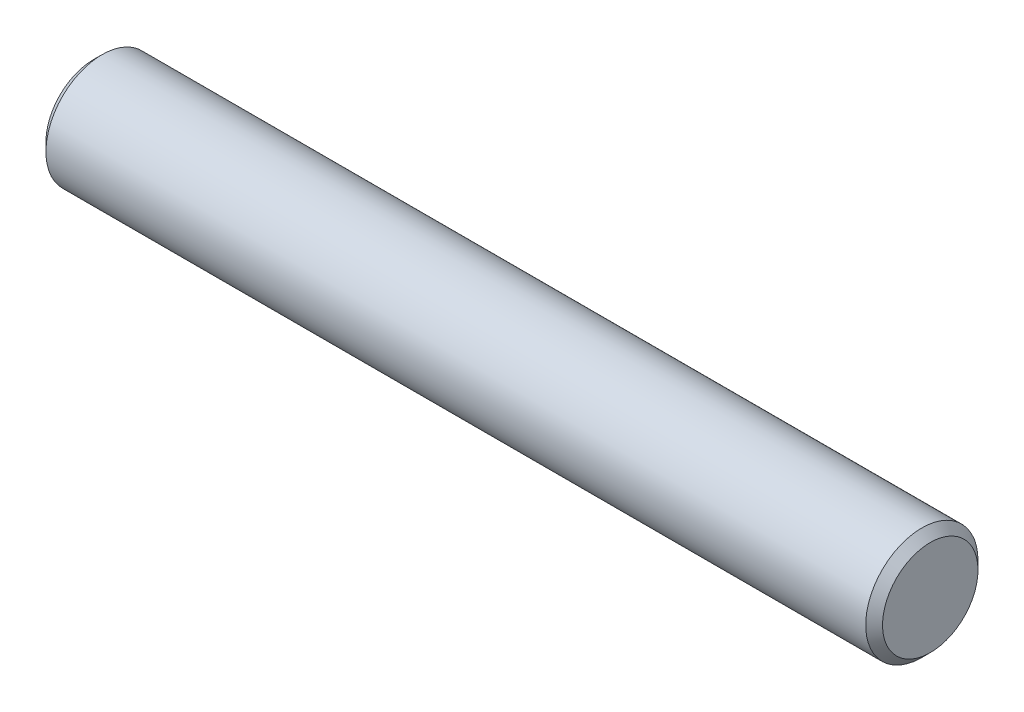
from build123d import *

# Parameters (mm, degrees)
SKETCH1_R           = 1
BOSS_EXTRUDE1_DEPTH = 7.45
CHAMFER1_SIZE       = 0.15


with BuildPart() as part:
    # Sketch1 → Boss-Extrude1 (new body, symmetric)
    with BuildSketch(Plane(origin=(0, 0, 0), x_dir=(0, 0, -1), z_dir=(1, 0, 0))):
        Circle(SKETCH1_R)
    extrude(amount=BOSS_EXTRUDE1_DEPTH, both=True)

    # Chamfer1
    chamfer1_edges = [part.edges().sort_by_distance(p)[0] for p in [
        (-7.45, 0, 1),
        (7.45, 0, 1),
    ]]
    chamfer(chamfer1_edges, length=CHAMFER1_SIZE)


solid = part.part
